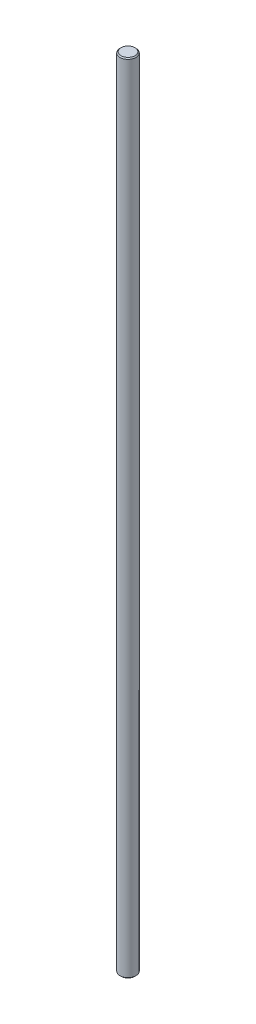
from build123d import *

# Parameters (mm, degrees)
SKETCH1_R           = 4
BOSS_EXTRUDE1_DEPTH = 400
CHAMFER1_SIZE       = 0.508


with BuildPart() as part:
    # Sketch1 → Boss-Extrude1 (new body)
    with BuildSketch(Plane(origin=(0, 0, 0), x_dir=(1, 0, 0), z_dir=(0, 1, 0))):
        Circle(SKETCH1_R)
    extrude(amount=BOSS_EXTRUDE1_DEPTH)

    # Chamfer1
    chamfer1_edges = [part.edges().sort_by_distance(p)[0] for p in [
        (-4, 0, 0),
        (-4, 400, 0),
    ]]
    chamfer(chamfer1_edges, length=CHAMFER1_SIZE)


solid = part.part
